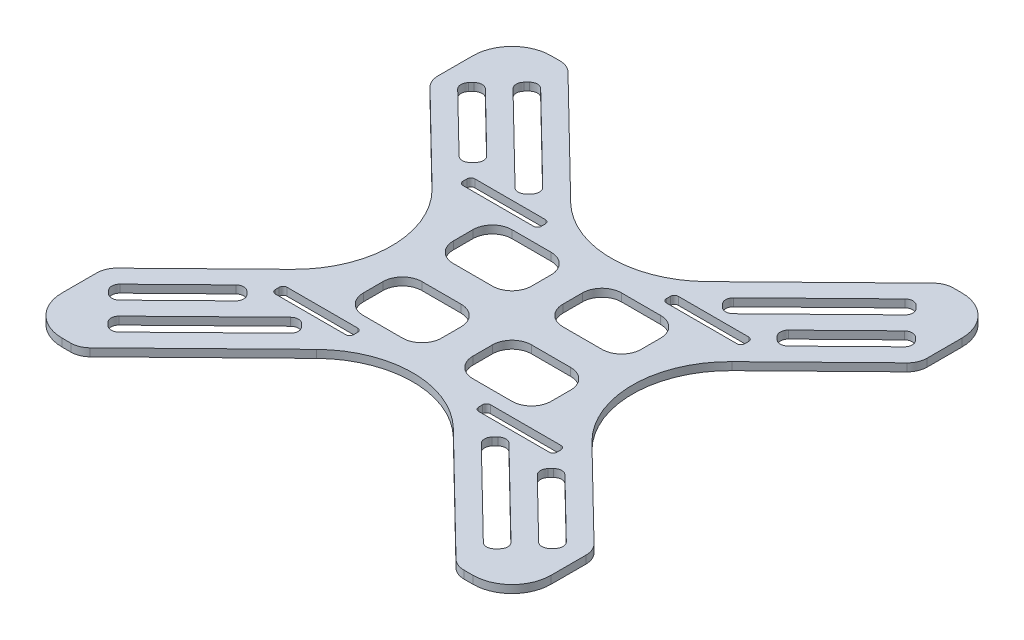
from build123d import *

# Parameters (mm, degrees)
SKETCH_1_W          = 125
SKETCH_1_H          = 125
SKETCH_1_W_2        = 20
SKETCH_1_H_2        = 3
EXTRUDE_1_DEPTH     = 2
FILLET_1_R          = 1
CUT_EXTRUDE_1_DEPTH = 3
FILLET_2_R          = 25
FILLET_3_R          = 10
FILLET_4_R          = 5
FILLET_5_R          = 5
SKETCH_3_W          = 20
SKETCH_3_H          = 15
CUT_EXTRUDE_2_DEPTH = 3
FILLET_7_R          = 5
FILLET_8_R          = 2


with BuildPart() as part:
    # 草图1 → 凸台-拉伸1 (new body)
    with BuildSketch(Plane(origin=(0, 0, 0), x_dir=(1, 0, 0), z_dir=(0, 1, 0))):
        Rectangle(SKETCH_1_W, SKETCH_1_H)
        with Locations((26, 24)):
            Rectangle(SKETCH_1_W_2, SKETCH_1_H_2, mode=Mode.SUBTRACT)
        with Locations((-26, 24)):
            Rectangle(SKETCH_1_W_2, SKETCH_1_H_2, mode=Mode.SUBTRACT)
        with Locations((26, -24)):
            Rectangle(SKETCH_1_W_2, SKETCH_1_H_2, mode=Mode.SUBTRACT)
        with Locations((-26, -24)):
            Rectangle(SKETCH_1_W_2, SKETCH_1_H_2, mode=Mode.SUBTRACT)
    extrude(amount=EXTRUDE_1_DEPTH)

    # 圆角1
    fillet_1_edges = [part.edges().sort_by_distance(p)[0] for p in [
        (-16, 1, -22.5),
        (-16, 1, -25.5),
        (-36, 1, -25.5),
        (-36, 1, -22.5),
        (36, 1, -22.5),
        (36, 1, -25.5),
        (16, 1, -25.5),
        (16, 1, -22.5),
        (36, 1, 22.5),
        (16, 1, 22.5),
        (16, 1, 25.5),
        (36, 1, 25.5),
        (-36, 1, 22.5),
        (-36, 1, 25.5),
        (-16, 1, 25.5),
        (-16, 1, 22.5),
    ]]
    fillet(fillet_1_edges, radius=FILLET_1_R)

    # 草图2 → 切除-拉伸1 (cut, through all)
    with BuildSketch(Plane(origin=(0, 2, 0), x_dir=(1, 0, 0), z_dir=(0, 1, 0))):
        Polygon((-62.5, 41.5), (-20, 0), (-62.5, -41.5), align=None)
        Polygon((62.5, 41.5), (20, 0), (62.5, -41.5), align=None)
        Polygon((-48.222181663, 62.5), (0, 15.412457906), (48.222181663, 62.5), align=None)
        Polygon((0, -15.412457906), (48.222181663, -62.5), (-48.222181663, -62.5), align=None)
    extrude(amount=-CUT_EXTRUDE_1_DEPTH, mode=Mode.SUBTRACT)

    # 圆角2
    fillet_2_edges = [part.edges().sort_by_distance(p)[0] for p in [
        (0, 1, -15.412457906),
        (20, 1, 0),
        (0, 1, 15.412457906),
        (-20, 1, 0),
    ]]
    fillet(fillet_2_edges, radius=FILLET_2_R)

    # 圆角3
    fillet_3_edges = [part.edges().sort_by_distance(p)[0] for p in [
        (62.5, 1, 62.5),
        (-62.5, 1, 62.5),
        (-62.5, 1, -62.5),
        (62.5, 1, -62.5),
    ]]
    fillet(fillet_3_edges, radius=FILLET_3_R)

    # 圆角4
    fillet_4_edges = [part.edges().sort_by_distance(p)[0] for p in [
        (62.5, 1, -41.5),
        (62.5, 1, 41.5),
        (-62.5, 1, 41.5),
        (-62.5, 1, -41.5),
    ]]
    fillet(fillet_4_edges, radius=FILLET_4_R)

    # 圆角5
    fillet_5_edges = [part.edges().sort_by_distance(p)[0] for p in [
        (-48.222181663, 1, -62.5),
        (48.222181663, 1, -62.5),
        (-48.222181663, 1, 62.5),
        (48.222181663, 1, 62.5),
    ]]
    fillet(fillet_5_edges, radius=FILLET_5_R)

    # 草图3 → 切除-拉伸2 (cut, through all)
    with BuildSketch(Plane(origin=(0, 2, 0), x_dir=(1, 0, 0), z_dir=(0, 1, 0))):
        Polygon((-51.511951971, 51.73561608), (-26.47036123, 27.283239239), (-22.977164539, 30.860609345), (-48.01875528, 55.312986186), align=None)
        Polygon((-58.498345354, 44.580875868), (-40.611494825, 27.11489241), (-37.118298134, 30.692262516), (-55.005148663, 48.158245974), align=None)
        with Locations((14, 11.5)):
            Rectangle(SKETCH_3_W, SKETCH_3_H)
        with Locations((-14, 11.5)):
            Rectangle(SKETCH_3_W, SKETCH_3_H)
        Polygon((48.01875528, 55.312986186), (51.511951971, 51.73561608), (26.47036123, 27.283239239), (22.977164539, 30.860609345), align=None)
        Polygon((37.118298134, 30.692262516), (55.005148663, 48.158245974), (58.498345354, 44.580875868), (40.611494825, 27.11489241), align=None)
        Polygon((-37.118298134, -30.692262516), (-55.005148663, -48.158245974), (-58.498345354, -44.580875868), (-40.611494825, -27.11489241), align=None)
        Polygon((-48.01875528, -55.312986186), (-51.511951971, -51.73561608), (-26.47036123, -27.283239239), (-22.977164539, -30.860609345), align=None)
        Polygon((40.611494825, -27.11489241), (37.118298134, -30.692262516), (55.005148663, -48.158245974), (58.498345354, -44.580875868), align=None)
        Polygon((22.977164539, -30.860609345), (48.01875528, -55.312986186), (51.511951971, -51.73561608), (26.47036123, -27.283239239), align=None)
        with Locations((14, -11.5)):
            Rectangle(SKETCH_3_W, SKETCH_3_H)
        with Locations((-14, -11.5)):
            Rectangle(SKETCH_3_W, SKETCH_3_H)
    extrude(amount=-CUT_EXTRUDE_2_DEPTH, mode=Mode.SUBTRACT)

    # 圆角7
    fillet_7_edges = [part.edges().sort_by_distance(p)[0] for p in [
        (-4, 1, -19),
        (-4, 1, -4),
        (-24, 1, -4),
        (-24, 1, -19),
        (4, 1, 4),
        (24, 1, 4),
        (24, 1, 19),
        (4, 1, 19),
        (-24, 1, 19),
        (-24, 1, 4),
        (-4, 1, 4),
        (-4, 1, 19),
        (24, 1, -19),
        (24, 1, -4),
        (4, 1, -4),
        (4, 1, -19),
    ]]
    fillet(fillet_7_edges, radius=FILLET_7_R)

    # 圆角8
    fillet_8_edges = [part.edges().sort_by_distance(p)[0] for p in [
        (40.611494825, 1, -27.11489241),
        (37.118298134, 1, -30.692262516),
        (55.005148663, 1, -48.158245974),
        (58.498345354, 1, -44.580875868),
        (-40.611494825, 1, 27.11489241),
        (-37.118298134, 1, 30.692262516),
        (-55.005148663, 1, 48.158245974),
        (-58.498345354, 1, 44.580875868),
        (-22.977164539, 1, 30.860609345),
        (-48.01875528, 1, 55.312986186),
        (-51.511951971, 1, 51.73561608),
        (-26.47036123, 1, 27.283239239),
        (40.611494825, 1, 27.11489241),
        (58.498345354, 1, 44.580875868),
        (55.005148663, 1, 48.158245974),
        (37.118298134, 1, 30.692262516),
        (-58.498345354, 1, -44.580875868),
        (-55.005148663, 1, -48.158245974),
        (-37.118298134, 1, -30.692262516),
        (-40.611494825, 1, -27.11489241),
        (-51.511951971, 1, -51.73561608),
        (-48.01875528, 1, -55.312986186),
        (-22.977164539, 1, -30.860609345),
        (-26.47036123, 1, -27.283239239),
        (22.977164539, 1, -30.860609345),
        (48.01875528, 1, -55.312986186),
        (51.511951971, 1, -51.73561608),
        (26.47036123, 1, -27.283239239),
        (22.977164539, 1, 30.860609345),
        (26.47036123, 1, 27.283239239),
        (51.511951971, 1, 51.73561608),
        (48.01875528, 1, 55.312986186),
    ]]
    fillet(fillet_8_edges, radius=FILLET_8_R)


solid = part.part
